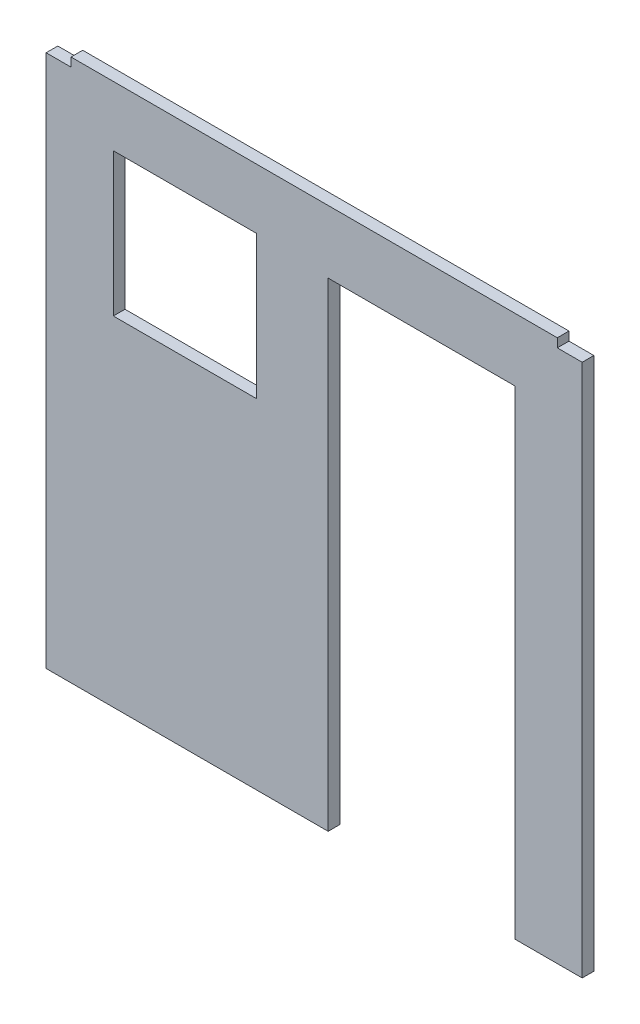
from build123d import *

# Parameters (mm, degrees)
BOSS_EXTRUDE1_DEPTH = 50.8
SKETCH2_W           = 622.3
SKETCH2_H           = 622.3
SKETCH2_W_2         = 812.8
SKETCH2_H_2         = 2082.8
CUT_EXTRUDE1_DEPTH  = 50.8


with BuildPart() as part:
    # Sketch1 → Boss-Extrude1 (new body)
    with BuildSketch(Plane.XY):
        Polygon((1057.021, 1178.179), (-1057.021, 1178.179), (-1057.021, 1140.079), (-1165.225, 1140.079), (-1165.225, -1178.179), (1165.225, -1178.179), (1165.225, 1140.079), (1057.021, 1140.079), align=None)
    extrude(amount=BOSS_EXTRUDE1_DEPTH)

    # Sketch2 → Cut-Extrude1 (cut)
    with BuildSketch(Plane.XY.offset(50.8)):
        with Locations((-561.975, 606.171)):
            Rectangle(SKETCH2_W, SKETCH2_H)
        with Locations((467.233, -136.779)):
            Rectangle(SKETCH2_W_2, SKETCH2_H_2)
    extrude(amount=-CUT_EXTRUDE1_DEPTH, mode=Mode.SUBTRACT)


solid = part.part
